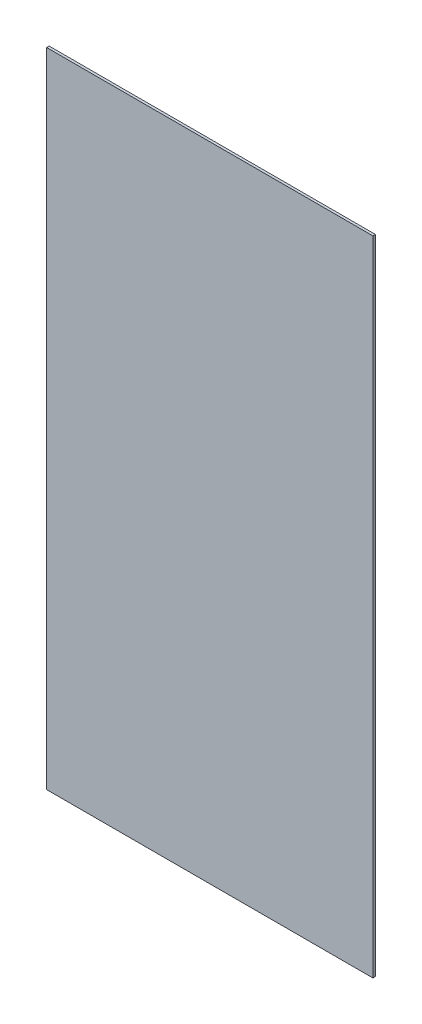
from build123d import *

# Parameters (mm, degrees)
SKETCH1_W           = 330.2
SKETCH1_H           = 650.24
BOSS_EXTRUDE1_DEPTH = 2.54


with BuildPart() as part:
    # Sketch1 → Boss-Extrude1 (new body)
    with BuildSketch(Plane.XY):
        with Locations((-52.724242424, 46.522683983)):
            Rectangle(SKETCH1_W, SKETCH1_H)
    extrude(amount=BOSS_EXTRUDE1_DEPTH)


solid = part.part
